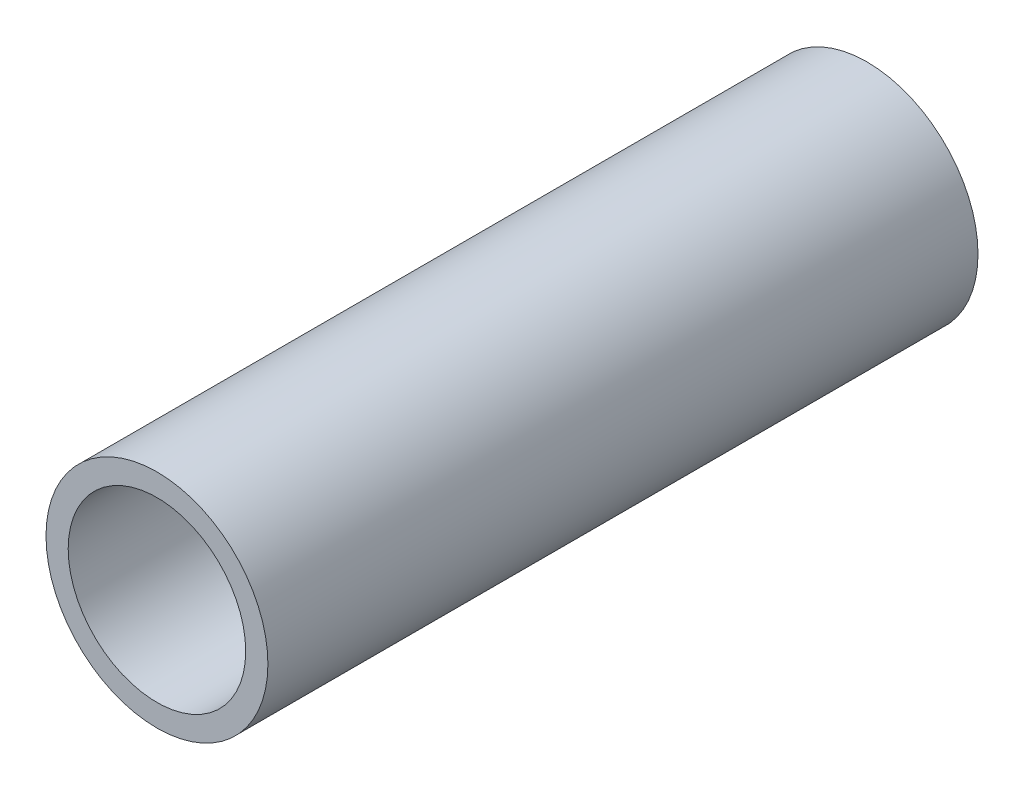
from build123d import *

# Parameters (mm, degrees)
SKETCH1_R           = 1.25
SKETCH1_R_2         = 1
BOSS_EXTRUDE1_DEPTH = 8


with BuildPart() as part:
    # Sketch1 → Boss-Extrude1 (new body)
    with BuildSketch(Plane.XY):
        Circle(SKETCH1_R)
        Circle(SKETCH1_R_2, mode=Mode.SUBTRACT)
    extrude(amount=BOSS_EXTRUDE1_DEPTH)


solid = part.part
